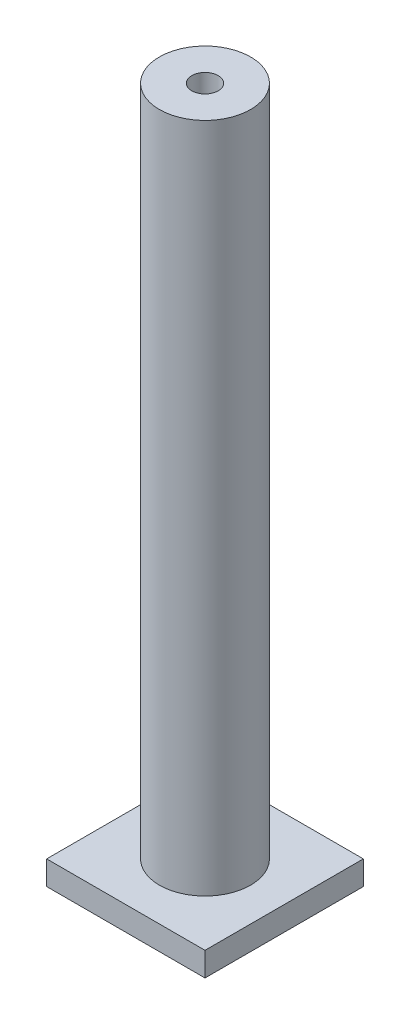
from build123d import *

# Parameters (mm, degrees)
SKETCH1_W           = 16.5
SKETCH1_H           = 16.5
SKETCH1_R           = 1.375
BOSS_EXTRUDE1_DEPTH = 2.5
SKETCH2_R           = 4.75
SKETCH2_R_2         = 1.375
BOSS_EXTRUDE2_DEPTH = 70


with BuildPart() as part:
    # Sketch1 → Boss-Extrude1 (new body)
    with BuildSketch(Plane(origin=(0, 0, 0), x_dir=(1, 0, 0), z_dir=(0, 1, 0))):
        with Locations((0.455521472, -1.417177914)):
            Rectangle(SKETCH1_W, SKETCH1_H)
        with Locations((0.455521472, -1.417177914)):
            Circle(SKETCH1_R, mode=Mode.SUBTRACT)
    extrude(amount=BOSS_EXTRUDE1_DEPTH)

    # Sketch2 → Boss-Extrude2 (add)
    with BuildSketch(Plane(origin=(0, 2.5, 0), x_dir=(1, 0, 0), z_dir=(0, 1, 0))):
        with Locations((0.455521472, -1.417177914)):
            Circle(SKETCH2_R)
        with Locations((0.455521472, -1.417177914)):
            Circle(SKETCH2_R_2, mode=Mode.SUBTRACT)
    extrude(amount=BOSS_EXTRUDE2_DEPTH)


solid = part.part
